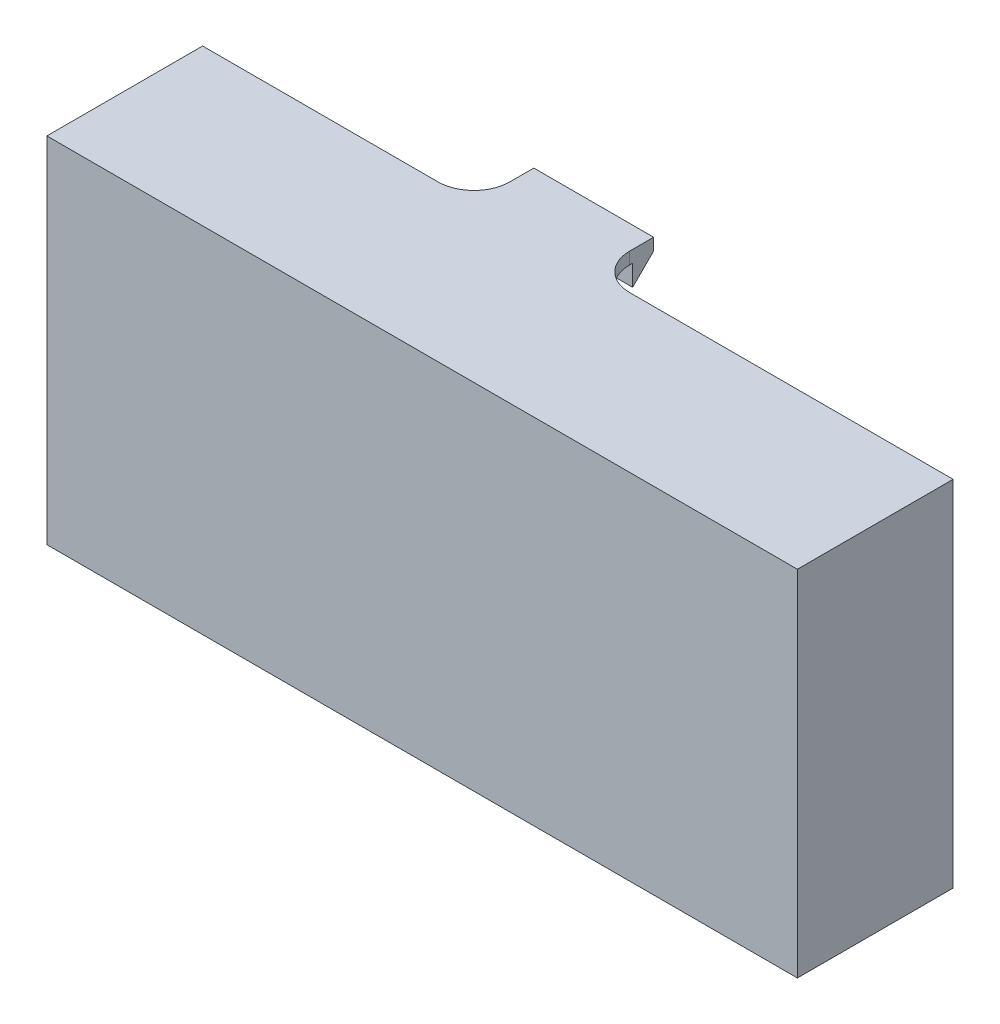
from build123d import *

# Parameters (mm, degrees)
SKETCH1_W            = 62.6472
SKETCH1_H            = 29.551
SKETCH1_W_2          = 60.6472
SKETCH1_H_2          = 27.551
BOSS_EXTRUDE1_DEPTH  = 11
CUT_EXTRUDE1_REACH   = 64.647
SKETCH4_W            = 2
SKETCH4_H            = 1
BOSS_EXTRUDE2_DEPTH  = 1
SKETCH6_W            = 2
SKETCH6_H            = 1
BOSS_EXTRUDE3_DEPTH  = 1
BOSS_EXTRUDE4_START  = -30
SKETCH7_W            = 1
SKETCH7_H            = 1
BOSS_EXTRUDE4_DEPTH  = 10
BOSS_EXTRUDE5_START  = 40
SKETCH9_W            = 1
SKETCH9_H            = 1.5
BOSS_EXTRUDE5_DEPTH  = 10
BOSS_EXTRUDE7_START  = -30
BOSS_EXTRUDE7_DEPTH  = 10
SKETCH12_W           = 62.6472
SKETCH12_H           = 29.551
BOSS_EXTRUDE8_DEPTH  = 2
BOSS_EXTRUDE9_DEPTH  = 1
BOSS_EXTRUDE10_START = -29.551
BOSS_EXTRUDE10_DEPTH = 1


with BuildPart() as part:
    # Sketch1 → Boss-Extrude1 (new body)
    with BuildSketch(Plane.XY):
        with Locations((-30.0736, 13.5255)):
            Rectangle(SKETCH1_W, SKETCH1_H)
        with Locations((-30.0736, 13.5255)):
            Rectangle(SKETCH1_W_2, SKETCH1_H_2, mode=Mode.SUBTRACT)
    extrude(amount=BOSS_EXTRUDE1_DEPTH)

    # Sketch3 → Cut-Extrude1 (cut, up to next)
    with BuildSketch(Plane.ZY.offset(61.3972), mode=Mode.PRIVATE) as cut_extrude1_sk1:
        Polygon((0, 17.5514), (0.75, 18.3233), (0.75, 24.3233), (0, 25.0952), align=None)
    cut_extrude1_tool1 = extrude(cut_extrude1_sk1.sketch, amount=-CUT_EXTRUDE1_REACH, mode=Mode.PRIVATE) & part.part
    add(cut_extrude1_tool1.solids().sort_by_distance((-61.3972, 21.3233, 0.360752))[0], mode=Mode.SUBTRACT)

    # Sketch4 → Boss-Extrude2 (add)
    with BuildSketch(Plane(origin=(0, -0.25, 0), x_dir=(1, 0, 0), z_dir=(0, 1, 0))):
        with Locations((-54.3972, -2.3375)):
            Rectangle(SKETCH4_W, SKETCH4_H)
        with Locations((-5.75, -2.3375)):
            Rectangle(SKETCH4_W, SKETCH4_H)
    extrude(amount=BOSS_EXTRUDE2_DEPTH)

    # Sketch6 → Boss-Extrude3 (add)
    with BuildSketch(Plane.XZ.offset(-27.301)):
        with Locations((-2.75, 2.3375)):
            Rectangle(SKETCH6_W, SKETCH6_H)
        with Locations((-51.3776, 2.783222425)):
            Rectangle(SKETCH6_W, SKETCH6_H)
    extrude(amount=BOSS_EXTRUDE3_DEPTH)

    # Sketch7 → Boss-Extrude4 (add)
    with BuildSketch(Plane(origin=(1.25, 0, 0), x_dir=(0, 0, -1), z_dir=(1, 0, 0)).offset(BOSS_EXTRUDE4_START)):
        with Locations((0.5, 27.451)):
            Rectangle(SKETCH7_W, SKETCH7_H)
    extrude(amount=-BOSS_EXTRUDE4_DEPTH)

    # Sketch9 → Boss-Extrude5 (add)
    with BuildSketch(Plane.ZY.offset(-1.25).offset(BOSS_EXTRUDE5_START)):
        with Locations((-0.5, -0.5)):
            Rectangle(SKETCH9_W, SKETCH9_H)
    extrude(amount=-BOSS_EXTRUDE5_DEPTH)

    # Sketch11 → Boss-Extrude7 (add)
    with BuildSketch(Plane(origin=(1.25, 0, 0), x_dir=(0, 0, -1), z_dir=(1, 0, 0)).offset(BOSS_EXTRUDE7_START)):
        Polygon((5, 28.301), (5, 27.301), (3.25, 25.551), (3.25, 27.301), (0, 27.301), (0, 28.301), align=None)
        Polygon((0, -1.25), (5, -1.25), (5, -0.25), (3.25, 1.5), (3.25, -0.25), (0, -0.25), align=None)
    extrude(amount=-BOSS_EXTRUDE7_DEPTH)

    # Sketch12 → Boss-Extrude8 (add)
    with BuildSketch(Plane.XY.offset(11)):
        with Locations((-30.0736, 13.5255)):
            Rectangle(SKETCH12_W, SKETCH12_H)
    extrude(amount=BOSS_EXTRUDE8_DEPTH)

    # Sketch13 → Boss-Extrude9 (add)
    with BuildSketch(Plane.XZ.offset(1.25)):
        with BuildLine():
            Line((-25.75, 0), (-28.75, 0))
            Line((-28.75, 0), (-28.75, -3))
            ThreePointArc((-28.75, -3), (-27.871320344, -0.878679656), (-25.75, 0))
        make_face()
        with BuildLine():
            Line((-41.75, 0), (-38.75, 0))
            Line((-38.75, 0), (-38.75, -3))
            ThreePointArc((-38.75, -3), (-39.628679656, -0.878679656), (-41.75, 0))
        make_face()
    extrude(amount=-BOSS_EXTRUDE9_DEPTH)

    # Sketch13_2 → Boss-Extrude10 (add)
    with BuildSketch(Plane.XZ.offset(1.25).offset(BOSS_EXTRUDE10_START)):
        with BuildLine():
            Line((-25.75, 0), (-28.75, 0))
            Line((-28.75, 0), (-28.75, -3))
            ThreePointArc((-28.75, -3), (-27.871320344, -0.878679656), (-25.75, 0))
        make_face()
        with BuildLine():
            Line((-41.75, 0), (-38.75, 0))
            Line((-38.75, 0), (-38.75, -3))
            ThreePointArc((-38.75, -3), (-39.628679656, -0.878679656), (-41.75, 0))
        make_face()
    extrude(amount=BOSS_EXTRUDE10_DEPTH)


solid = part.part
